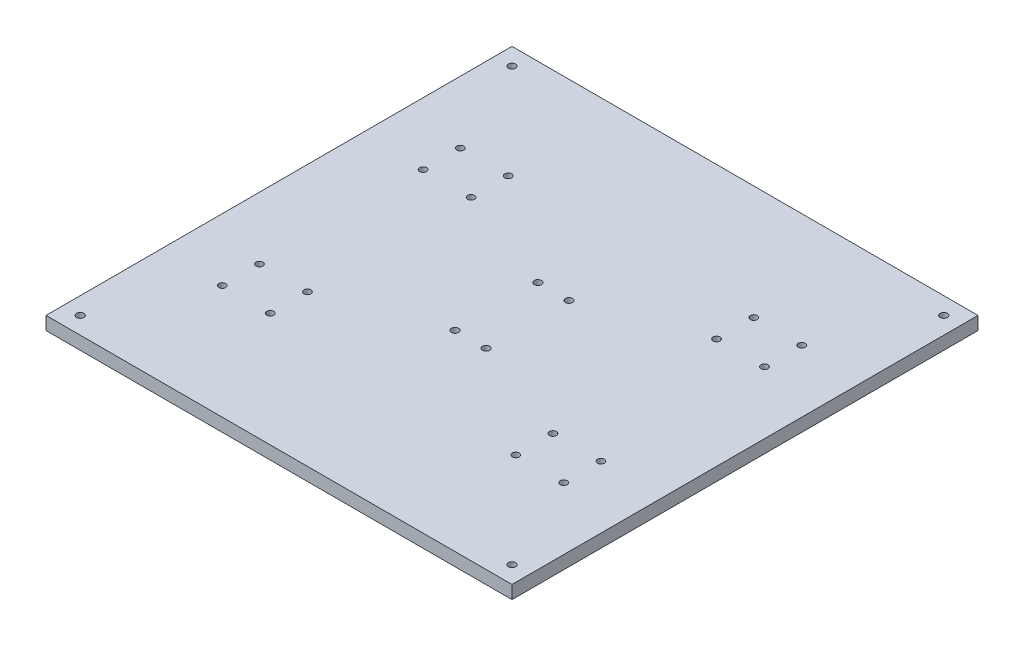
from build123d import *

# Parameters (mm, degrees)
SKETCH1_W           = 225
SKETCH1_H           = 225
BOSS_EXTRUDE1_DEPTH = 6.35
SKETCH2_R           = 1.75
CUT_EXTRUDE1_DEPTH  = 7.35
SKETCH3_R           = 1.75
CUT_EXTRUDE2_DEPTH  = 7.35
SKETCH4_R           = 1.675
CUT_EXTRUDE3_DEPTH  = 7.35


with BuildPart() as part:
    # Sketch1 → Boss-Extrude1 (new body)
    with BuildSketch(Plane(origin=(0, 0, 0), x_dir=(1, 0, 0), z_dir=(0, 1, 0))):
        with Locations((112.5, 112.5)):
            Rectangle(SKETCH1_W, SKETCH1_H)
    extrude(amount=BOSS_EXTRUDE1_DEPTH)

    # Sketch2 → Cut-Extrude1 (cut, through all)
    with BuildSketch(Plane(origin=(0, 6.35, 0), x_dir=(1, 0, 0), z_dir=(0, 1, 0))):
        with Locations((216.74, 216.74)):
            Circle(SKETCH2_R)
        with Locations((8.26, 216.74)):
            Circle(SKETCH2_R)
        with Locations((216.74, 8.26)):
            Circle(SKETCH2_R)
        with Locations((8.26, 8.26)):
            Circle(SKETCH2_R)
    extrude(amount=-CUT_EXTRUDE1_DEPTH, mode=Mode.SUBTRACT)

    # Sketch3 → Cut-Extrude2 (cut, through all)
    with BuildSketch(Plane(origin=(0, 6.35, 0), x_dir=(1, 0, 0), z_dir=(0, 1, 0))):
        with Locations((120, 132.5)):
            Circle(SKETCH3_R)
        with Locations((120, 92.5)):
            Circle(SKETCH3_R)
        with Locations((105, 92.5)):
            Circle(SKETCH3_R)
        with Locations((105, 132.5)):
            Circle(SKETCH3_R)
    extrude(amount=-CUT_EXTRUDE2_DEPTH, mode=Mode.SUBTRACT)

    # Sketch4 → Cut-Extrude3 (cut, through all)
    with BuildSketch(Plane.XZ):
        with Locations((171.76, -55.04)):
            Circle(SKETCH4_R)
        with Locations((194.92, -55.04)):
            Circle(SKETCH4_R)
        with Locations((194.92, -72.99)):
            Circle(SKETCH4_R)
        with Locations((171.76, -72.99)):
            Circle(SKETCH4_R)
        with Locations((30.08, -72.99)):
            Circle(SKETCH4_R)
        with Locations((53.24, -72.99)):
            Circle(SKETCH4_R)
        with Locations((53.24, -55.04)):
            Circle(SKETCH4_R)
        with Locations((30.08, -55.04)):
            Circle(SKETCH4_R)
        with Locations((30.08, -169.96)):
            Circle(SKETCH4_R)
        with Locations((53.24, -169.96)):
            Circle(SKETCH4_R)
        with Locations((53.24, -152.01)):
            Circle(SKETCH4_R)
        with Locations((30.08, -152.01)):
            Circle(SKETCH4_R)
        with Locations((171.76, -152.01)):
            Circle(SKETCH4_R)
        with Locations((194.92, -152.01)):
            Circle(SKETCH4_R)
        with Locations((194.92, -169.96)):
            Circle(SKETCH4_R)
        with Locations((171.76, -169.96)):
            Circle(SKETCH4_R)
    extrude(amount=-CUT_EXTRUDE3_DEPTH, mode=Mode.SUBTRACT)


solid = part.part
